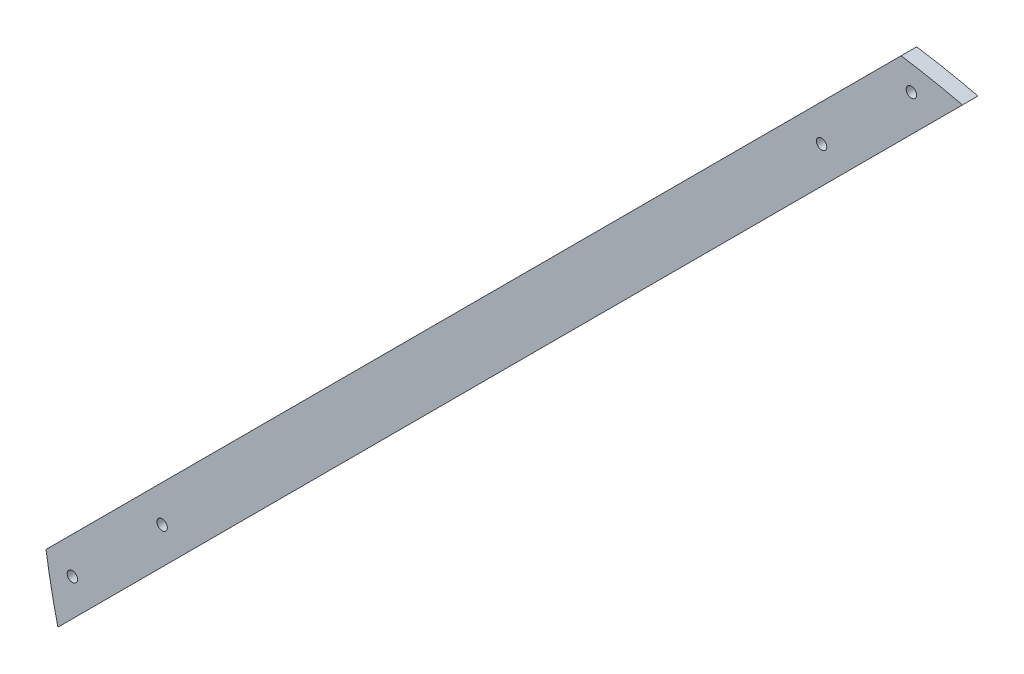
from build123d import *

# Parameters (mm, degrees)
BOSS_EXTRU_1_DEPTH      = 3
ESQUISSE2_R             = 1
ENL_V_MAT_EXTRU_1_DEPTH = 3


with BuildPart() as part:
    # Esquisse1 → Boss.-Extru.1 (new body)
    with BuildSketch(Plane.XY):
        with BuildLine():
            Line((33.50283922, 141.076432349), (21.213203436, 128.786796564))
            Line((21.213203436, 128.786796564), (-128.786796564, -21.213203436))
            Line((-128.786796564, -21.213203436), (-141.076432349, -33.50283922))
            ThreePointArc((-141.076432349, -33.50283922), (-142.348197514, -27.604178387), (-143.373440746, -21.657711993))
            Line((-143.373440746, -21.657711993), (-135.857864376, -14.142135624))
            Line((-135.857864376, -14.142135624), (14.142135624, 135.857864376))
            Line((14.142135624, 135.857864376), (21.657711993, 143.373440746))
            ThreePointArc((21.657711993, 143.373440746), (27.604178387, 142.348197514), (33.50283922, 141.076432349))
        make_face()
    extrude(amount=BOSS_EXTRU_1_DEPTH)

    # Esquisse2 → Enlèv. mat.-Extru.1 (cut)
    with BuildSketch(Plane.XY.offset(3)):
        with Locations((6.317279836, 120.961940777)):
            Circle(ESQUISSE2_R)
        with Locations((-120.961940777, -6.317279836)):
            Circle(ESQUISSE2_R)
        with Locations((23.641395976, 138.286056916)):
            Circle(ESQUISSE2_R)
        with Locations((-138.286056916, -23.641395976)):
            Circle(ESQUISSE2_R)
    extrude(amount=-ENL_V_MAT_EXTRU_1_DEPTH, mode=Mode.SUBTRACT)


solid = part.part
